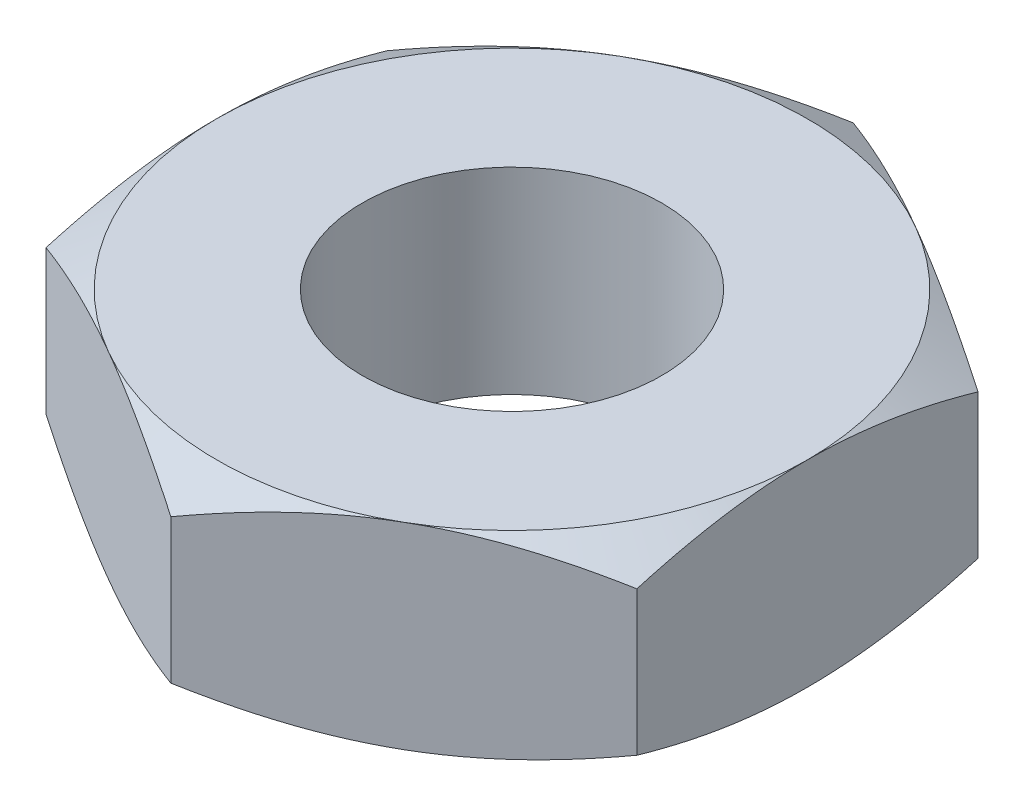
from build123d import *

# Parameters (mm, degrees)
SKETCH1_R               = 2.413
BOSS_EXTRUDE1_DEPTH     = 1.5875
SKETCH5_OUTSIDE_W       = 45.464
SKETCH5_OUTSIDE_H       = 46.936
SKETCH5_OUTSIDE_R       = 4.7625
CUT_EXTRUDE2_DEPTH      = 8.9375
CUT_EXTRUDE2_DRAFT      = -60
MIRROR1_COPY_1_SKETCH_W = 45.464
MIRROR1_COPY_1_SKETCH_H = 46.936
MIRROR1_COPY_1_SKETCH_R = 4.7625
MIRROR1_COPY_1_DEPTH    = 8.9375
MIRROR1_COPY_1_DRAFT    = -60


with BuildPart() as part:
    # Sketch1 → Boss-Extrude1 (new, symmetric)
    with BuildSketch(Plane(origin=(0, 0, 0), x_dir=(1, 0, 0), z_dir=(0, 1, 0))):
        Polygon((-4.7625, 2.749630657), (-4.7625, -2.749630657), (0, -5.499261314), (4.7625, -2.749630657), (4.7625, 2.749630657), (0, 5.499261314), align=None)
        Circle(SKETCH1_R, mode=Mode.SUBTRACT)
    extrude(amount=BOSS_EXTRUDE1_DEPTH, both=True)


with BuildPart() as cut_extrude2_tool:
    # Sketch5 outside → Cut-Extrude2 (with draft: the straight prism first)
    with BuildSketch(Plane(origin=(0, 1.5875, 0), x_dir=(1, 0, 0), z_dir=(0, 1, 0))):
        Rectangle(SKETCH5_OUTSIDE_W, SKETCH5_OUTSIDE_H)
        Circle(SKETCH5_OUTSIDE_R, mode=Mode.SUBTRACT)
    extrude(amount=-CUT_EXTRUDE2_DEPTH)
    # Cut-Extrude2: the draft: its side faces are tilted about the plane it starts from
    cut_extrude2_sides = [cut_extrude2_tool.faces().sort_by_distance(p)[0] for p in [
        (0, -2.88125, 23.468),
        (22.732, -2.88125, 0),
        (0, -2.88125, -23.468),
        (-22.732, -2.88125, 0),
        (-4.7625, -2.88125, 0),
    ]]
    draft(cut_extrude2_sides, Plane(origin=(0, 1.5875, 0), x_dir=(1, 0, 0), z_dir=(0, 1, 0)), CUT_EXTRUDE2_DRAFT)


with BuildPart() as part_1:
    add(part.part)

    # Cut-Extrude2: cut by cut_extrude2_tool
    add(cut_extrude2_tool.part, mode=Mode.SUBTRACT)


with BuildPart() as mirror1_copy_1_tool:
    # Mirror1 copy 1 sketch → Mirror1 copy 1 (with draft: the straight prism first)
    with BuildSketch(Plane.XZ.offset(1.5875)):
        Rectangle(MIRROR1_COPY_1_SKETCH_W, MIRROR1_COPY_1_SKETCH_H)
        Circle(MIRROR1_COPY_1_SKETCH_R, mode=Mode.SUBTRACT)
    extrude(amount=-MIRROR1_COPY_1_DEPTH)
    # Mirror1 copy 1: the draft: its side faces are tilted about the plane it starts from
    mirror1_copy_1_sides = [mirror1_copy_1_tool.faces().sort_by_distance(p)[0] for p in [
        (0, 2.88125, 23.468),
        (22.732, 2.88125, 0),
        (0, 2.88125, -23.468),
        (-22.732, 2.88125, 0),
        (-4.7625, 2.88125, 0),
    ]]
    draft(mirror1_copy_1_sides, Plane.XZ.offset(1.5875), MIRROR1_COPY_1_DRAFT)


with BuildPart() as part_2:
    add(part_1.part)

    # Mirror1 copy 1: cut by mirror1_copy_1_tool
    add(mirror1_copy_1_tool.part, mode=Mode.SUBTRACT)


solid = part_2.part
